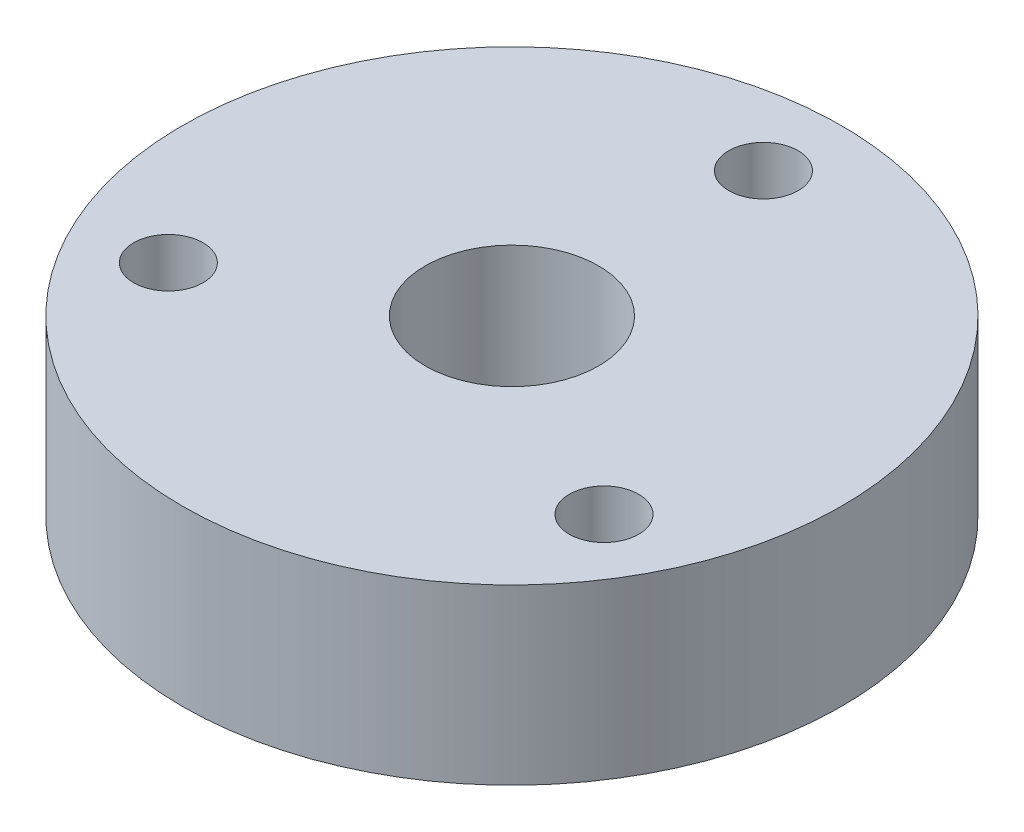
from build123d import *

# Parameters (mm, degrees)
SKETCH1_R           = 19
SKETCH1_R_2         = 2
SKETCH1_R_3         = 5
BOSS_EXTRUDE1_DEPTH = 10


with BuildPart() as part:
    # Sketch1 → Boss-Extrude1 (new body)
    with BuildSketch(Plane(origin=(0, 0, 0), x_dir=(1, 0, 0), z_dir=(0, 1, 0))):
        Circle(SKETCH1_R)
        with Locations((0, 14.5)):
            Circle(SKETCH1_R_2, mode=Mode.SUBTRACT)
        with Locations((12.557368355, -7.25)):
            Circle(SKETCH1_R_2, mode=Mode.SUBTRACT)
        with Locations((-12.557368355, -7.25)):
            Circle(SKETCH1_R_2, mode=Mode.SUBTRACT)
        Circle(SKETCH1_R_3, mode=Mode.SUBTRACT)
    extrude(amount=BOSS_EXTRUDE1_DEPTH)


solid = part.part
